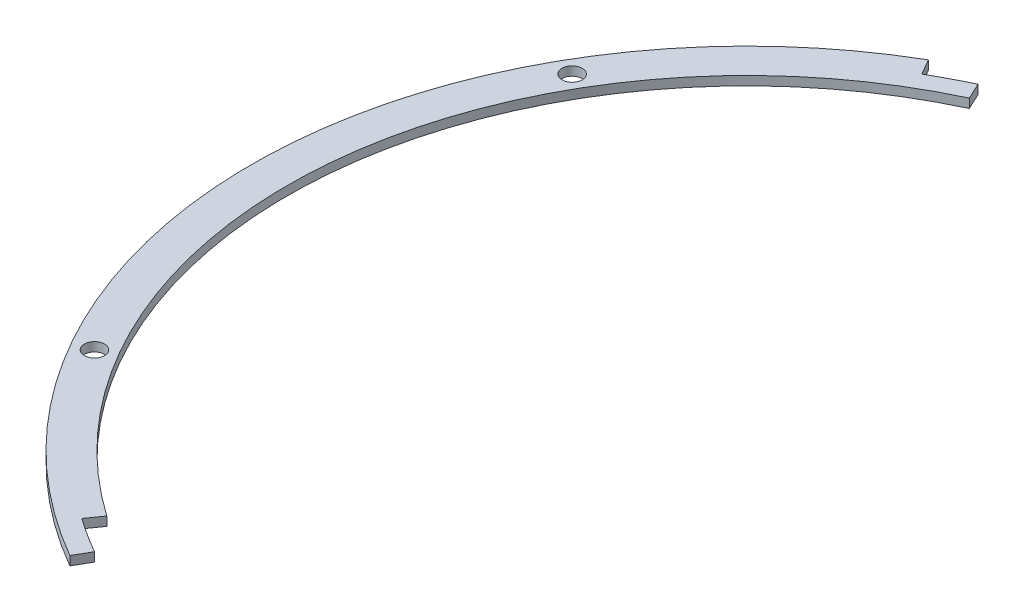
from build123d import *

# Parameters (mm, degrees)
SKETCH1_R           = 174.85
SKETCH1_R_2         = 3.556
SKETCH1_R_3         = 162.15
BOSS_EXTRUDE1_DEPTH = 3.175
CUT_EXTRUDE1_DEPTH  = 4.175


with BuildPart() as part:
    # Sketch1 → Boss-Extrude1 (new body)
    with BuildSketch(Plane(origin=(0, 0, 0), x_dir=(1, 0, 0), z_dir=(0, 1, 0))):
        Circle(SKETCH1_R)
        with Locations((0, 168.5)):
            Circle(SKETCH1_R_2, mode=Mode.SUBTRACT)
        with Locations((145.925280538, 84.25)):
            Circle(SKETCH1_R_2, mode=Mode.SUBTRACT)
        with Locations((145.925280538, -84.25)):
            Circle(SKETCH1_R_2, mode=Mode.SUBTRACT)
        with Locations((0, -168.5)):
            Circle(SKETCH1_R_2, mode=Mode.SUBTRACT)
        with Locations((-145.925280538, -84.25)):
            Circle(SKETCH1_R_2, mode=Mode.SUBTRACT)
        with Locations((-145.925280538, 84.25)):
            Circle(SKETCH1_R_2, mode=Mode.SUBTRACT)
        Circle(SKETCH1_R_3, mode=Mode.SUBTRACT)
    extrude(amount=BOSS_EXTRUDE1_DEPTH)

    # Sketch2 → Cut-Extrude1 (cut, through all)
    with BuildSketch(Plane(origin=(0, 0, 0), x_dir=(1, 0, 0), z_dir=(0, 1, 0))):
        with BuildLine():
            Line((-88.9, 153.979316793), (-84.25, 145.925280538))
            ThreePointArc((-84.25, 145.925280538), (-77.80464133, 149.461325391), (-71.211177103, 152.712862116))
            Line((-71.211177103, 152.712862116), (-68.527551141, 146.957807668))
            ThreePointArc((-68.527551141, 146.957807668), (-74.872537636, 143.8288066), (-81.075, 140.426019224))
            Line((-81.075, 140.426019224), (0, 0))
            Line((0, 0), (-81.075, -140.426019224))
            ThreePointArc((-81.075, -140.426019224), (-87.123131493, -136.755922939), (-93.005419154, -132.825503981))
            Line((-93.005419154, -132.825503981), (-96.647629525, -138.027119463))
            ThreePointArc((-96.647629525, -138.027119463), (-90.534984006, -142.111458619), (-84.25, -145.925280538))
            Line((-84.25, -145.925280538), (-87.425, -151.424541852))
            Line((-87.425, -151.424541852), (-88.9, -153.979316793))
            ThreePointArc((-88.9, -153.979316793), (177.8, 0), (-88.9, 153.979316793))
        make_face()
    extrude(amount=CUT_EXTRUDE1_DEPTH, mode=Mode.SUBTRACT)


solid = part.part
